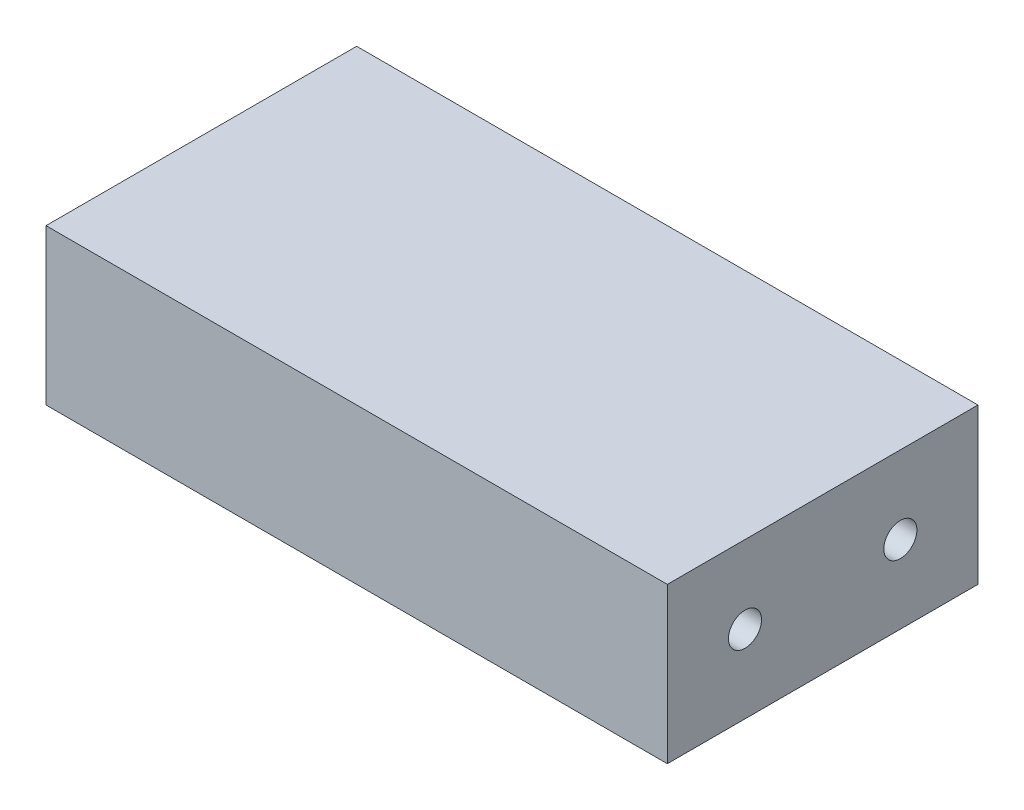
from build123d import *

# Parameters (mm, degrees)
SKETCH1_W                      = 50.8
SKETCH1_H                      = 25.4
BOSS_EXTRUDE1_DEPTH            = 12.7
F_6_32_TAPPED_HOLE1_AT_2_COUNT = 2
F_6_32_TAPPED_HOLE1_AT_2_PITCH = 12.7


with BuildPart() as part:
    # Sketch1 → Boss-Extrude1 (new body)
    with BuildSketch(Plane(origin=(0, 0, 0), x_dir=(1, 0, 0), z_dir=(0, 1, 0))):
        with Locations((-0.6, 6.366666667)):
            Rectangle(SKETCH1_W, SKETCH1_H)
    extrude(amount=BOSS_EXTRUDE1_DEPTH)

    # Sketch3 → #6-32 Tapped Hole1 (revolve, cut)
    with BuildSketch(Plane(origin=(24.8, 6.35, -0.016666667), x_dir=(0, 0, -1), z_dir=(0, 1, 0))):
        Polygon((0, 0), (0, 13.51269403), (1.35255, 12.7), (1.35255, 0), align=None)
    f_6_32_tapped_hole1 = revolve(axis=Axis((31.15, 6.35, -0.016666667), (-1, 0, 0)), mode=Mode.SUBTRACT)

    # #6-32 Tapped Hole1 at 2: #6-32 Tapped Hole1 ×2
    with Locations(*[(0, 0, -i * F_6_32_TAPPED_HOLE1_AT_2_PITCH) for i in range(1, F_6_32_TAPPED_HOLE1_AT_2_COUNT)]):
        add(f_6_32_tapped_hole1, mode=Mode.SUBTRACT)

    # Mirror1: #6-32 Tapped Hole1 across plane
    add(f_6_32_tapped_hole1.mirror(Plane(origin=(-0.6, 0, 0), x_dir=(0, 0, 1), z_dir=(1, 0, 0))), mode=Mode.SUBTRACT)

    # Mirror1 copy 1 sketch → Mirror1 copy 1 (revolve, cut)
    with BuildSketch(Plane(origin=(-26, 6.35, -12.716666667), x_dir=(0, 0, -1), z_dir=(0, 1, 0))):
        Polygon((0, 0), (0, -13.51269403), (1.35255, -12.7), (1.35255, 0), align=None)
    revolve(axis=Axis((-32.35, 6.35, -12.716666667), (-1, 0, 0)), mode=Mode.SUBTRACT)


solid = part.part
